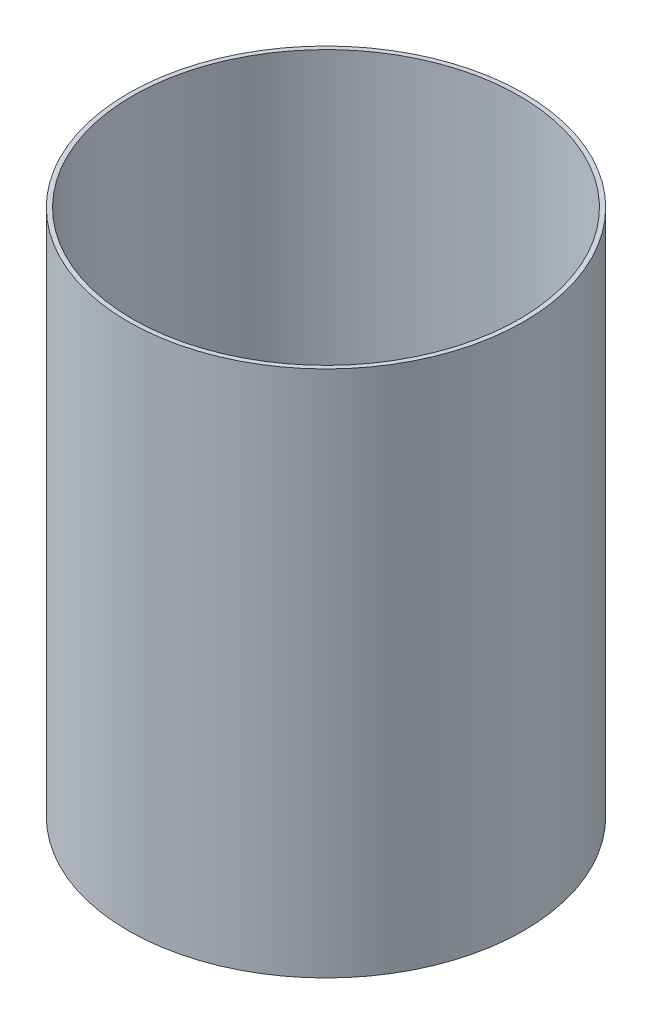
from build123d import *

# Parameters (mm, degrees)
SKETCH1_R           = 225
BOSS_EXTRUDE1_DEPTH = 600
SHELL1_T            = -5


with BuildPart() as part:
    # Sketch1 → Boss-Extrude1 (new body)
    with BuildSketch(Plane(origin=(0, 0, 0), x_dir=(1, 0, 0), z_dir=(0, 1, 0))):
        with Locations(Location((0, 0, 0), (0, 0, 270))):
            Circle(SKETCH1_R)
    extrude(amount=BOSS_EXTRUDE1_DEPTH)

    # Shell1
    shell1_openings = [part.faces().sort_by_distance(p)[0] for p in [
        (0, 600, 0),
    ]]
    offset(amount=SHELL1_T, openings=shell1_openings, kind=Kind.INTERSECTION)


solid = part.part
